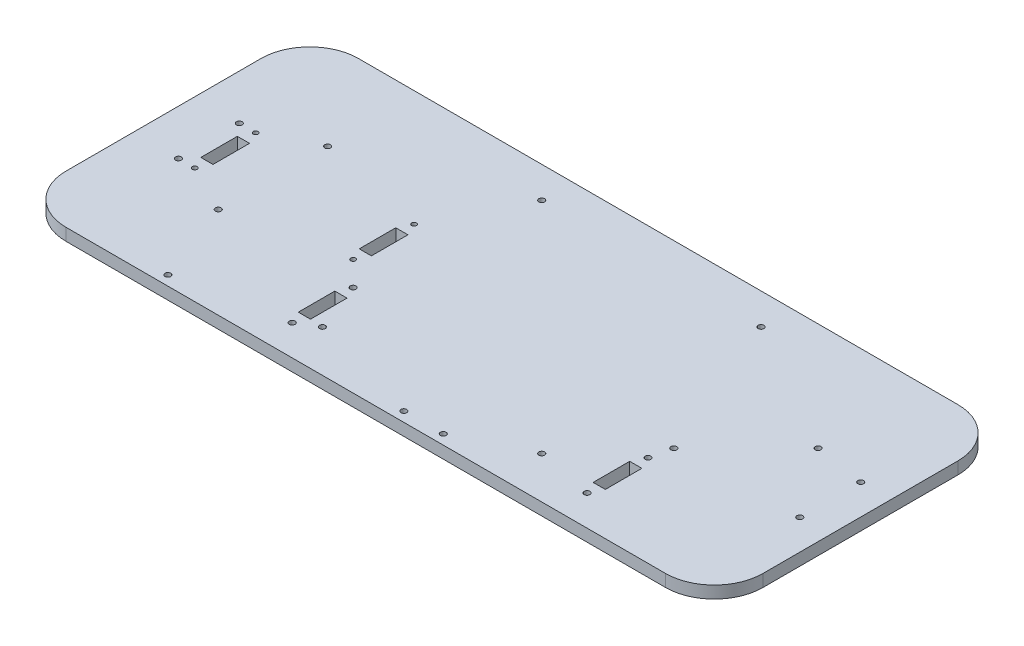
from build123d import *

# Parameters (mm, degrees)
BOSS_EXTRUDE2_DEPTH = 6.35
SKETCH4_R           = 1.5
CUT_EXTRUDE1_DEPTH  = 6.35
SKETCH5_R           = 1.25
SKETCH5_W           = 6.35
SKETCH5_H           = 19.05
CUT_EXTRUDE2_DEPTH  = 6.35
SKETCH6_R           = 1.5
CUT_EXTRUDE3_DEPTH  = 6.35
SKETCH7_R           = 1.5
SKETCH7_W           = 6.35
SKETCH7_H           = 19.05
CUT_EXTRUDE4_DEPTH  = 6.35
SKETCH9_R           = 1.5
CUT_EXTRUDE6_DEPTH  = 6.35
SKETCH10_R          = 1.5
CUT_EXTRUDE7_DEPTH  = 7.35


with BuildPart() as part:
    # Sketch3 → Boss-Extrude2 (new body)
    with BuildSketch(Plane(origin=(0, 0, 0), x_dir=(1, 0, 0), z_dir=(0, 1, 0))):
        with BuildLine():
            Line((-156.21, -76.2), (156.21, -76.2))
            ThreePointArc((156.21, -76.2), (174.170512242, -68.760512242), (181.61, -50.8))
            Line((181.61, -50.8), (181.61, 50.8))
            ThreePointArc((181.61, 50.8), (174.170512242, 68.760512242), (156.21, 76.2))
            Line((156.21, 76.2), (-156.21, 76.2))
            ThreePointArc((-156.21, 76.2), (-174.170512242, 68.760512242), (-181.61, 50.8))
            Line((-181.61, 50.8), (-181.61, -50.8))
            ThreePointArc((-181.61, -50.8), (-174.170512242, -68.760512242), (-156.21, -76.2))
        make_face()
    extrude(amount=-BOSS_EXTRUDE2_DEPTH)

    # Sketch4 → Cut-Extrude1 (cut)
    with BuildSketch(Plane(origin=(0, 0, 0), x_dir=(1, 0, 0), z_dir=(0, 1, 0))):
        with Locations((-44.45, 59.944)):
            Circle(SKETCH4_R)
        with Locations((69.85, 59.944)):
            Circle(SKETCH4_R)
        with Locations((69.85, -54.356)):
            Circle(SKETCH4_R)
        with Locations((-44.45, -54.356)):
            Circle(SKETCH4_R)
        with Locations((139.446, 20.066)):
            Circle(SKETCH4_R)
        with Locations((101.854, -17.526)):
            Circle(SKETCH4_R)
    extrude(amount=-CUT_EXTRUDE1_DEPTH, mode=Mode.SUBTRACT)

    # Sketch5 → Cut-Extrude2 (cut)
    with BuildSketch(Plane(origin=(0, 0, 0), x_dir=(1, 0, 0), z_dir=(0, 1, 0))):
        with Locations((-149.479, 15.875)):
            Circle(SKETCH5_R)
        with Locations((-149.479, -15.875)):
            Circle(SKETCH5_R)
        with Locations((-66.929, -15.875)):
            Circle(SKETCH5_R)
        with Locations((-66.929, 15.875)):
            Circle(SKETCH5_R)
        with Locations((-149.479, 0)):
            Rectangle(SKETCH5_W, SKETCH5_H)
        with Locations((-66.929, 0)):
            Rectangle(SKETCH5_W, SKETCH5_H)
    extrude(amount=-CUT_EXTRUDE2_DEPTH, mode=Mode.SUBTRACT)

    # Sketch6 → Cut-Extrude3 (cut)
    with BuildSketch(Plane(origin=(0, 0, 0), x_dir=(1, 0, 0), z_dir=(0, 1, 0))):
        with Locations((-157.988, 15.875)):
            Circle(SKETCH6_R)
        with Locations((-157.988, -15.875)):
            Circle(SKETCH6_R)
        with Locations((165.862, -15.875)):
            Circle(SKETCH6_R)
        with Locations((165.862, 15.875)):
            Circle(SKETCH6_R)
    extrude(amount=-CUT_EXTRUDE3_DEPTH, mode=Mode.SUBTRACT)

    # Sketch7 → Cut-Extrude4 (cut)
    with BuildSketch(Plane(origin=(0, 0, 0), x_dir=(1, 0, 0), z_dir=(0, 1, 0))):
        with Locations((-54.229, -28.575)):
            Circle(SKETCH7_R)
        with Locations((-54.229, -60.325)):
            Circle(SKETCH7_R)
        with Locations((99.441, -60.325)):
            Circle(SKETCH7_R)
        with Locations((99.441, -28.575)):
            Circle(SKETCH7_R)
        with Locations((99.441, -44.45)):
            Rectangle(SKETCH7_W, SKETCH7_H)
        with Locations((-54.229, -44.45)):
            Rectangle(SKETCH7_W, SKETCH7_H)
    extrude(amount=-CUT_EXTRUDE4_DEPTH, mode=Mode.SUBTRACT)

    # Sketch9 → Cut-Extrude6 (cut)
    with BuildSketch(Plane(origin=(0, 0, 0), x_dir=(1, 0, 0), z_dir=(0, 1, 0))):
        with Locations((-108.204, -71.12)):
            Circle(SKETCH9_R)
        with Locations((14.732, -71.12)):
            Circle(SKETCH9_R)
        with Locations((35.306, -71.12)):
            Circle(SKETCH9_R)
    extrude(amount=-CUT_EXTRUDE6_DEPTH, mode=Mode.SUBTRACT)

    # Sketch10 → Cut-Extrude7 (cut, through all)
    with BuildSketch(Plane(origin=(0, 0, 0), x_dir=(1, 0, 0), z_dir=(0, 1, 0))):
        with Locations((-124.61, 28.5)):
            Circle(SKETCH10_R)
        with Locations((-124.61, -28.5)):
            Circle(SKETCH10_R)
    extrude(amount=-CUT_EXTRUDE7_DEPTH, mode=Mode.SUBTRACT)


solid = part.part
